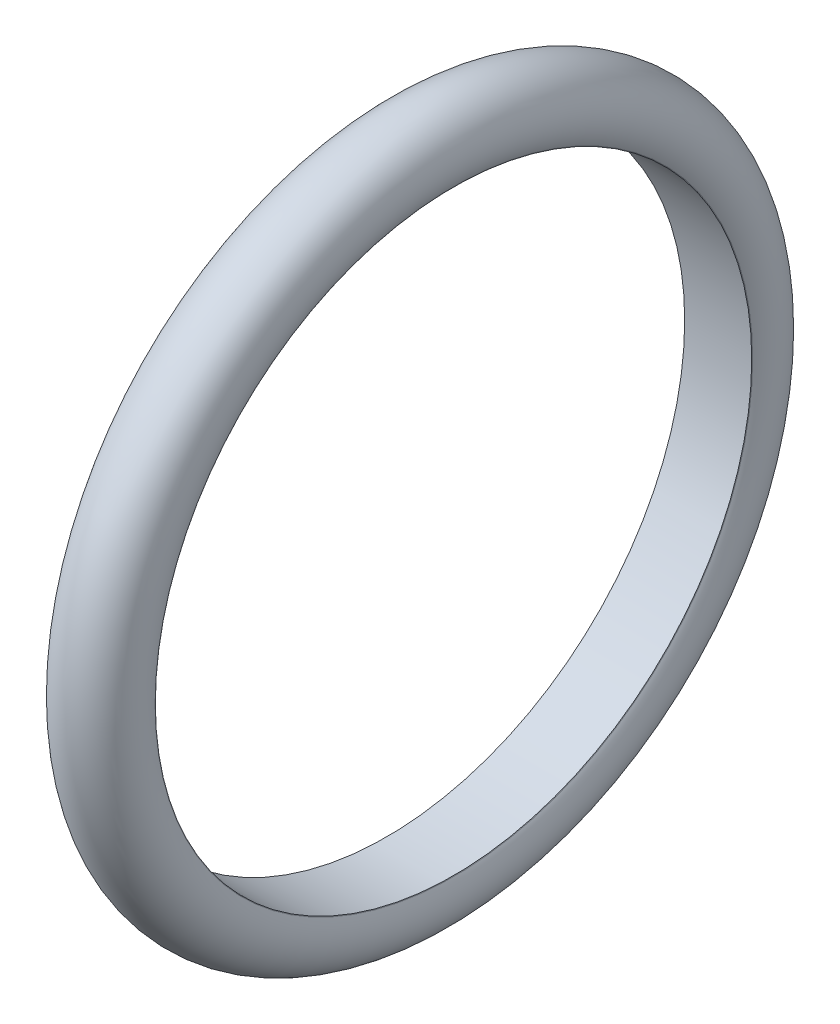
from build123d import *


with BuildPart() as part:
    # Sketch1 → Revolve1 (revolve)
    with BuildSketch(Plane.XY):
        with BuildLine():
            Line((-19.247414599, 169.8625), (-19.05, 169.520567884))
            Line((-19.05, 169.520567884), (19.05, 169.520567884))
            Line((19.05, 169.520567884), (19.247414599, 169.8625))
            ThreePointArc((19.247414599, 169.8625), (0, 203.2), (-19.247414599, 169.8625))
        make_face()
    revolve(axis=Axis((0, 0, 0), (1, 0, 0)))


solid = part.part
